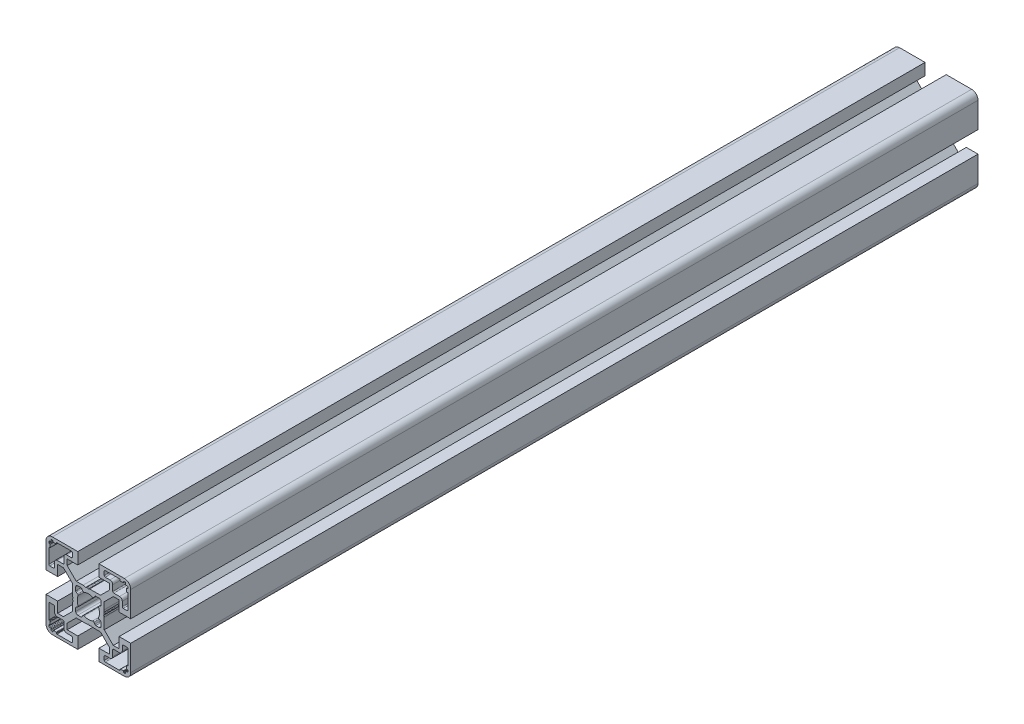
from build123d import *

# Parameters (mm, degrees)
BOSS_EXTRUDE1_DEPTH = 400


with BuildPart() as part:
    # Sketch1 → Boss-Extrude1 (new body)
    with BuildSketch(Plane.XY):
        with BuildLine():
            Line((-11.767766953, -10), (-14.5, -10))
            Line((-14.5, -10), (-14.5, -5))
            Line((-14.5, -5), (-20, -5))
            Line((-20, -5), (-20, -17))
            ThreePointArc((-20, -17), (-19.121320344, -19.121320344), (-17, -20))
            Line((-17, -20), (-5, -20))
            Line((-5, -20), (-5, -14.5))
            Line((-5, -14.5), (-10, -14.5))
            Line((-10, -14.5), (-10, -11.767766953))
            Line((-10, -11.767766953), (-5.732233047, -7.5))
            Line((-5.732233047, -7.5), (-0.653589838, -7.5))
            ThreePointArc((-0.653589838, -7.5), (-0.524180316, -7.482962913), (-0.403589838, -7.433012702))
            Line((-0.403589838, -7.433012702), (0, -7.2))
            Line((0, -7.2), (0.403589838, -7.433012702))
            ThreePointArc((0.403589838, -7.433012702), (0.653589838, -7.5), (0.903589838, -7.433012702))
            Line((0.903589838, -7.433012702), (1.218885629, -7.250976592))
            Line((1.218885629, -7.250976592), (2.5, -7.5))
            Line((2.5, -7.5), (5.732233047, -7.5))
            Line((5.732233047, -7.5), (10, -11.767766953))
            Line((10, -11.767766953), (10, -14.5))
            Line((10, -14.5), (5, -14.5))
            Line((5, -14.5), (5, -20))
            Line((5, -20), (17, -20))
            ThreePointArc((17, -20), (19.121320344, -19.121320344), (20, -17))
            Line((20, -17), (20, -5))
            Line((20, -5), (14.5, -5))
            Line((14.5, -5), (14.5, -10))
            Line((14.5, -10), (11.767766953, -10))
            Line((11.767766953, -10), (7.5, -5.732233047))
            Line((7.5, -5.732233047), (7.5, -0.653589838))
            ThreePointArc((7.5, -0.653589838), (7.482962913, -0.524180316), (7.433012702, -0.403589838))
            Line((7.433012702, -0.403589838), (7.2, 0))
            Line((7.2, 0), (7.433012702, 0.403589838))
            ThreePointArc((7.433012702, 0.403589838), (7.5, 0.653589838), (7.433012702, 0.903589838))
            Line((7.433012702, 0.903589838), (7.250976592, 1.218885629))
            Line((7.250976592, 1.218885629), (7.5, 2.5))
            Line((7.5, 2.5), (7.5, 5.732233047))
            Line((7.5, 5.732233047), (11.767766953, 10))
            Line((11.767766953, 10), (14.5, 10))
            Line((14.5, 10), (14.5, 5))
            Line((14.5, 5), (20, 5))
            Line((20, 5), (20, 17))
            ThreePointArc((20, 17), (19.121320344, 19.121320344), (17, 20))
            Line((17, 20), (5, 20))
            Line((5, 20), (5, 14.5))
            Line((5, 14.5), (10, 14.5))
            Line((10, 14.5), (10, 11.767766953))
            Line((10, 11.767766953), (5.732233047, 7.5))
            Line((5.732233047, 7.5), (0.653589838, 7.5))
            ThreePointArc((0.653589838, 7.5), (0.524180316, 7.482962913), (0.403589838, 7.433012702))
            Line((0.403589838, 7.433012702), (0, 7.2))
            Line((0, 7.2), (-0.403589838, 7.433012702))
            ThreePointArc((-0.403589838, 7.433012702), (-0.653589838, 7.5), (-0.903589838, 7.433012702))
            Line((-0.903589838, 7.433012702), (-1.218885629, 7.250976592))
            Line((-1.218885629, 7.250976592), (-2.5, 7.5))
            Line((-2.5, 7.5), (-5.732233047, 7.5))
            Line((-5.732233047, 7.5), (-10, 11.767766953))
            Line((-10, 11.767766953), (-10, 14.5))
            Line((-10, 14.5), (-5, 14.5))
            Line((-5, 14.5), (-5, 20))
            Line((-5, 20), (-17, 20))
            ThreePointArc((-17, 20), (-19.121320344, 19.121320344), (-20, 17))
            Line((-20, 17), (-20, 5))
            Line((-20, 5), (-14.5, 5))
            Line((-14.5, 5), (-14.5, 10))
            Line((-14.5, 10), (-11.767766953, 10))
            Line((-11.767766953, 10), (-7.5, 5.732233047))
            Line((-7.5, 5.732233047), (-7.5, 0.653589838))
            ThreePointArc((-7.5, 0.653589838), (-7.482962913, 0.524180316), (-7.433012702, 0.403589838))
            Line((-7.433012702, 0.403589838), (-7.2, 0))
            Line((-7.2, 0), (-7.433012702, -0.403589838))
            ThreePointArc((-7.433012702, -0.403589838), (-7.5, -0.653589838), (-7.433012702, -0.903589838))
            Line((-7.433012702, -0.903589838), (-7.250976592, -1.218885629))
            Line((-7.250976592, -1.218885629), (-7.5, -2.5))
            Line((-7.5, -2.5), (-7.5, -5.732233047))
            Line((-7.5, -5.732233047), (-11.767766953, -10))
        make_face()
        with BuildLine():
            Line((7.5, 16.5), (7.5, 18.2))
            ThreePointArc((7.5, 18.2), (7.646446609, 18.553553391), (8, 18.7))
            Line((8, 18.7), (14.8, 18.7))
            ThreePointArc((14.8, 18.7), (14.941421356, 18.641421356), (15, 18.5))
            Line((15, 18.5), (15, 18.2))
            ThreePointArc((15, 18.2), (15.058578644, 18.058578644), (15.2, 18))
            Line((15.2, 18), (16.4, 18))
            ThreePointArc((16.4, 18), (16.541421356, 18.058578644), (16.6, 18.2))
            Line((16.6, 18.2), (16.6, 18.5))
            ThreePointArc((16.6, 18.5), (16.658578644, 18.641421356), (16.8, 18.7))
            Line((16.8, 18.7), (17.3, 18.7))
            ThreePointArc((17.3, 18.7), (17.512132034, 18.612132034), (17.6, 18.4))
            Line((17.6, 18.4), (17.6, 17.9))
            ThreePointArc((17.6, 17.9), (17.687867966, 17.687867966), (17.9, 17.6))
            Line((17.9, 17.6), (18.4, 17.6))
            ThreePointArc((18.4, 17.6), (18.612132034, 17.512132034), (18.7, 17.3))
            Line((18.7, 17.3), (18.7, 16.8))
            ThreePointArc((18.7, 16.8), (18.641421356, 16.658578644), (18.5, 16.6))
            Line((18.5, 16.6), (18.2, 16.6))
            ThreePointArc((18.2, 16.6), (18.058578644, 16.541421356), (18, 16.4))
            Line((18, 16.4), (18, 15.2))
            ThreePointArc((18, 15.2), (18.058578644, 15.058578644), (18.2, 15))
            Line((18.2, 15), (18.5, 15))
            ThreePointArc((18.5, 15), (18.641421356, 14.941421356), (18.7, 14.8))
            Line((18.7, 14.8), (18.7, 8))
            ThreePointArc((18.7, 8), (18.553553391, 7.646446609), (18.2, 7.5))
            Line((18.2, 7.5), (16.5, 7.5))
            ThreePointArc((16.5, 7.5), (16.146446609, 7.646446609), (16, 8))
            Line((16, 8), (16, 10.2))
            ThreePointArc((16, 10.2), (15.619238816, 11.119238816), (14.7, 11.5))
            Line((14.7, 11.5), (12, 11.5))
            ThreePointArc((12, 11.5), (11.646446609, 11.646446609), (11.5, 12))
            Line((11.5, 12), (11.5, 14.7))
            ThreePointArc((11.5, 14.7), (11.119238816, 15.619238816), (10.2, 16))
            Line((10.2, 16), (8, 16))
            ThreePointArc((8, 16), (7.646446609, 16.146446609), (7.5, 16.5))
        make_face(mode=Mode.SUBTRACT)
        with BuildLine():
            Line((14.8, -18.7), (8, -18.7))
            ThreePointArc((8, -18.7), (7.646446609, -18.553553391), (7.5, -18.2))
            Line((7.5, -18.2), (7.5, -16.5))
            ThreePointArc((7.5, -16.5), (7.646446609, -16.146446609), (8, -16))
            Line((8, -16), (10.2, -16))
            ThreePointArc((10.2, -16), (11.119238816, -15.619238816), (11.5, -14.7))
            Line((11.5, -14.7), (11.5, -12))
            ThreePointArc((11.5, -12), (11.646446609, -11.646446609), (12, -11.5))
            Line((12, -11.5), (14.7, -11.5))
            ThreePointArc((14.7, -11.5), (15.619238816, -11.119238816), (16, -10.2))
            Line((16, -10.2), (16, -8))
            ThreePointArc((16, -8), (16.146446609, -7.646446609), (16.5, -7.5))
            Line((16.5, -7.5), (18.2, -7.5))
            ThreePointArc((18.2, -7.5), (18.553553391, -7.646446609), (18.7, -8))
            Line((18.7, -8), (18.7, -14.8))
            ThreePointArc((18.7, -14.8), (18.641421356, -14.941421356), (18.5, -15))
            Line((18.5, -15), (18.2, -15))
            ThreePointArc((18.2, -15), (18.058578644, -15.058578644), (18, -15.2))
            Line((18, -15.2), (18, -16.4))
            ThreePointArc((18, -16.4), (18.058578644, -16.541421356), (18.2, -16.6))
            Line((18.2, -16.6), (18.5, -16.6))
            ThreePointArc((18.5, -16.6), (18.641421356, -16.658578644), (18.7, -16.8))
            Line((18.7, -16.8), (18.7, -17.3))
            ThreePointArc((18.7, -17.3), (18.612132034, -17.512132034), (18.4, -17.6))
            Line((18.4, -17.6), (17.9, -17.6))
            ThreePointArc((17.9, -17.6), (17.687867966, -17.687867966), (17.6, -17.9))
            Line((17.6, -17.9), (17.6, -18.4))
            ThreePointArc((17.6, -18.4), (17.512132034, -18.612132034), (17.3, -18.7))
            Line((17.3, -18.7), (16.8, -18.7))
            ThreePointArc((16.8, -18.7), (16.658578644, -18.641421356), (16.6, -18.5))
            Line((16.6, -18.5), (16.6, -18.2))
            ThreePointArc((16.6, -18.2), (16.541421356, -18.058578644), (16.4, -18))
            Line((16.4, -18), (15.2, -18))
            ThreePointArc((15.2, -18), (15.058578644, -18.058578644), (15, -18.2))
            Line((15, -18.2), (15, -18.5))
            ThreePointArc((15, -18.5), (14.941421356, -18.641421356), (14.8, -18.7))
        make_face(mode=Mode.SUBTRACT)
        with BuildLine():
            Line((-18.7, 16.8), (-18.7, 17.3))
            ThreePointArc((-18.7, 17.3), (-18.612132034, 17.512132034), (-18.4, 17.6))
            Line((-18.4, 17.6), (-17.9, 17.6))
            ThreePointArc((-17.9, 17.6), (-17.687867966, 17.687867966), (-17.6, 17.9))
            Line((-17.6, 17.9), (-17.6, 18.4))
            ThreePointArc((-17.6, 18.4), (-17.512132034, 18.612132034), (-17.3, 18.7))
            Line((-17.3, 18.7), (-16.8, 18.7))
            ThreePointArc((-16.8, 18.7), (-16.658578644, 18.641421356), (-16.6, 18.5))
            Line((-16.6, 18.5), (-16.6, 18.2))
            ThreePointArc((-16.6, 18.2), (-16.541421356, 18.058578644), (-16.4, 18))
            Line((-16.4, 18), (-15.2, 18))
            ThreePointArc((-15.2, 18), (-15.058578644, 18.058578644), (-15, 18.2))
            Line((-15, 18.2), (-15, 18.5))
            ThreePointArc((-15, 18.5), (-14.941421356, 18.641421356), (-14.8, 18.7))
            Line((-14.8, 18.7), (-8, 18.7))
            ThreePointArc((-8, 18.7), (-7.646446609, 18.553553391), (-7.5, 18.2))
            Line((-7.5, 18.2), (-7.5, 16.5))
            ThreePointArc((-7.5, 16.5), (-7.646446609, 16.146446609), (-8, 16))
            Line((-8, 16), (-10.2, 16))
            ThreePointArc((-10.2, 16), (-11.119238816, 15.619238816), (-11.5, 14.7))
            Line((-11.5, 14.7), (-11.5, 12))
            ThreePointArc((-11.5, 12), (-11.646446609, 11.646446609), (-12, 11.5))
            Line((-12, 11.5), (-14.7, 11.5))
            ThreePointArc((-14.7, 11.5), (-15.619238816, 11.119238816), (-16, 10.2))
            Line((-16, 10.2), (-16, 8))
            ThreePointArc((-16, 8), (-16.146446609, 7.646446609), (-16.5, 7.5))
            Line((-16.5, 7.5), (-18.2, 7.5))
            ThreePointArc((-18.2, 7.5), (-18.553553391, 7.646446609), (-18.7, 8))
            Line((-18.7, 8), (-18.7, 14.8))
            ThreePointArc((-18.7, 14.8), (-18.641421356, 14.941421356), (-18.5, 15))
            Line((-18.5, 15), (-18.2, 15))
            ThreePointArc((-18.2, 15), (-18.058578644, 15.058578644), (-18, 15.2))
            Line((-18, 15.2), (-18, 16.4))
            ThreePointArc((-18, 16.4), (-18.058578644, 16.541421356), (-18.2, 16.6))
            Line((-18.2, 16.6), (-18.5, 16.6))
            ThreePointArc((-18.5, 16.6), (-18.641421356, 16.658578644), (-18.7, 16.8))
        make_face(mode=Mode.SUBTRACT)
        with BuildLine():
            Line((-18.7, -14.8), (-18.7, -8))
            ThreePointArc((-18.7, -8), (-18.553553391, -7.646446609), (-18.2, -7.5))
            Line((-18.2, -7.5), (-16.5, -7.5))
            ThreePointArc((-16.5, -7.5), (-16.146446609, -7.646446609), (-16, -8))
            Line((-16, -8), (-16, -10.2))
            ThreePointArc((-16, -10.2), (-15.619238816, -11.119238816), (-14.7, -11.5))
            Line((-14.7, -11.5), (-12, -11.5))
            ThreePointArc((-12, -11.5), (-11.646446609, -11.646446609), (-11.5, -12))
            Line((-11.5, -12), (-11.5, -14.7))
            ThreePointArc((-11.5, -14.7), (-11.119238816, -15.619238816), (-10.2, -16))
            Line((-10.2, -16), (-8, -16))
            ThreePointArc((-8, -16), (-7.646446609, -16.146446609), (-7.5, -16.5))
            Line((-7.5, -16.5), (-7.5, -18.2))
            ThreePointArc((-7.5, -18.2), (-7.646446609, -18.553553391), (-8, -18.7))
            Line((-8, -18.7), (-14.8, -18.7))
            ThreePointArc((-14.8, -18.7), (-14.941421356, -18.641421356), (-15, -18.5))
            Line((-15, -18.5), (-15, -18.2))
            ThreePointArc((-15, -18.2), (-15.058578644, -18.058578644), (-15.2, -18))
            Line((-15.2, -18), (-16.4, -18))
            ThreePointArc((-16.4, -18), (-16.541421356, -18.058578644), (-16.6, -18.2))
            Line((-16.6, -18.2), (-16.6, -18.5))
            ThreePointArc((-16.6, -18.5), (-16.658578644, -18.641421356), (-16.8, -18.7))
            Line((-16.8, -18.7), (-17.3, -18.7))
            ThreePointArc((-17.3, -18.7), (-17.512132034, -18.612132034), (-17.6, -18.4))
            Line((-17.6, -18.4), (-17.6, -17.9))
            ThreePointArc((-17.6, -17.9), (-17.687867966, -17.687867966), (-17.9, -17.6))
            Line((-17.9, -17.6), (-18.4, -17.6))
            ThreePointArc((-18.4, -17.6), (-18.612132034, -17.512132034), (-18.7, -17.3))
            Line((-18.7, -17.3), (-18.7, -16.8))
            ThreePointArc((-18.7, -16.8), (-18.641421356, -16.658578644), (-18.5, -16.6))
            Line((-18.5, -16.6), (-18.2, -16.6))
            ThreePointArc((-18.2, -16.6), (-18.058578644, -16.541421356), (-18, -16.4))
            Line((-18, -16.4), (-18, -15.2))
            ThreePointArc((-18, -15.2), (-18.058578644, -15.058578644), (-18.2, -15))
            Line((-18.2, -15), (-18.5, -15))
            ThreePointArc((-18.5, -15), (-18.641421356, -14.941421356), (-18.7, -14.8))
        make_face(mode=Mode.SUBTRACT)
        with BuildLine():
            Line((-6, 3.490686899), (-6, 5))
            ThreePointArc((-6, 5), (-5.707106781, 5.707106781), (-5, 6))
            Line((-5, 6), (-3.490686899, 6))
            ThreePointArc((-3.490686899, 6), (-3.233167862, 5.92858365), (-3.049213103, 5.734735781))
            Line((-3.049213103, 5.734735781), (-2.689236216, 5.057717724))
            ThreePointArc((-2.689236216, 5.057717724), (-2.414618721, 4.821116073), (-2.052304818, 4.832240157))
            ThreePointArc((-2.052304818, 4.832240157), (0, 5.25), (2.052304818, 4.832240157))
            ThreePointArc((2.052304818, 4.832240157), (2.414618721, 4.821116073), (2.689236216, 5.057717724))
            Line((2.689236216, 5.057717724), (3.049213103, 5.734735781))
            ThreePointArc((3.049213103, 5.734735781), (3.233167862, 5.92858365), (3.490686899, 6))
            Line((3.490686899, 6), (5, 6))
            ThreePointArc((5, 6), (5.707106781, 5.707106781), (6, 5))
            Line((6, 5), (6, 3.490686899))
            ThreePointArc((6, 3.490686899), (5.92858365, 3.233167862), (5.734735781, 3.049213103))
            Line((5.734735781, 3.049213103), (5.057717724, 2.689236216))
            ThreePointArc((5.057717724, 2.689236216), (4.821116073, 2.414618721), (4.832240157, 2.052304818))
            ThreePointArc((4.832240157, 2.052304818), (5.25, 0), (4.832240157, -2.052304818))
            ThreePointArc((4.832240157, -2.052304818), (4.821116073, -2.414618721), (5.057717724, -2.689236216))
            Line((5.057717724, -2.689236216), (5.734735781, -3.049213103))
            ThreePointArc((5.734735781, -3.049213103), (5.92858365, -3.233167862), (6, -3.490686899))
            Line((6, -3.490686899), (6, -5))
            ThreePointArc((6, -5), (5.707106781, -5.707106781), (5, -6))
            Line((5, -6), (3.490686899, -6))
            ThreePointArc((3.490686899, -6), (3.233167862, -5.92858365), (3.049213103, -5.734735781))
            Line((3.049213103, -5.734735781), (2.689236216, -5.057717724))
            ThreePointArc((2.689236216, -5.057717724), (2.414618721, -4.821116073), (2.052304818, -4.832240157))
            ThreePointArc((2.052304818, -4.832240157), (0, -5.25), (-2.052304818, -4.832240157))
            ThreePointArc((-2.052304818, -4.832240157), (-2.414618721, -4.821116073), (-2.689236216, -5.057717724))
            Line((-2.689236216, -5.057717724), (-3.049213103, -5.734735781))
            ThreePointArc((-3.049213103, -5.734735781), (-3.233167862, -5.92858365), (-3.490686899, -6))
            Line((-3.490686899, -6), (-5, -6))
            ThreePointArc((-5, -6), (-5.707106781, -5.707106781), (-6, -5))
            Line((-6, -5), (-6, -3.490686899))
            ThreePointArc((-6, -3.490686899), (-5.92858365, -3.233167862), (-5.734735781, -3.049213103))
            Line((-5.734735781, -3.049213103), (-5.057717724, -2.689236216))
            ThreePointArc((-5.057717724, -2.689236216), (-4.821116073, -2.414618721), (-4.832240157, -2.052304818))
            ThreePointArc((-4.832240157, -2.052304818), (-5.25, 0), (-4.832240157, 2.052304818))
            ThreePointArc((-4.832240157, 2.052304818), (-4.821116073, 2.414618721), (-5.057717724, 2.689236216))
            Line((-5.057717724, 2.689236216), (-5.734735781, 3.049213103))
            ThreePointArc((-5.734735781, 3.049213103), (-5.92858365, 3.233167862), (-6, 3.490686899))
        make_face(mode=Mode.SUBTRACT)
    extrude(amount=-BOSS_EXTRUDE1_DEPTH)


solid = part.part
